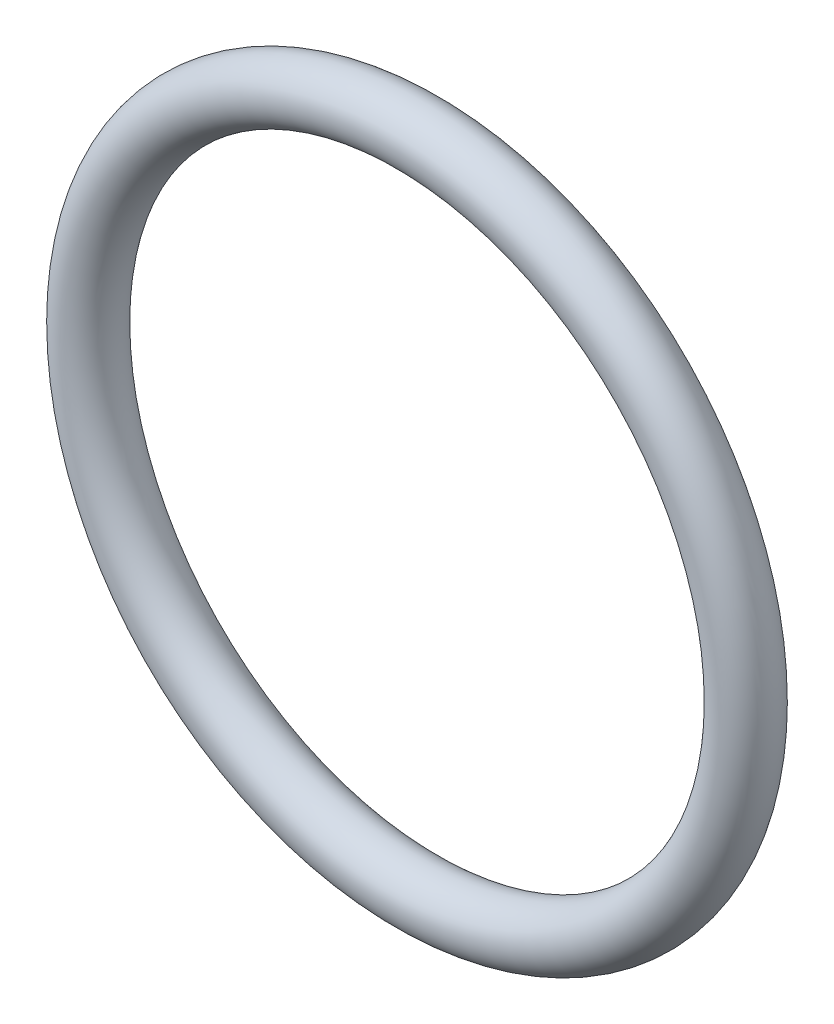
from build123d import *

# Parameters (mm, degrees)
SKETCH1_R = 1.3081


with BuildPart() as part:
    # Sketch1 → Revolve1 (revolve)
    with BuildSketch(Plane(origin=(0, 0, 0), x_dir=(0, -1, 0), z_dir=(1, 0, 0))):
        with Locations((14.6304, 0)):
            Circle(SKETCH1_R)
    revolve(axis=Axis((0, 0, 1.3081), (0, 0, -1)))


solid = part.part
